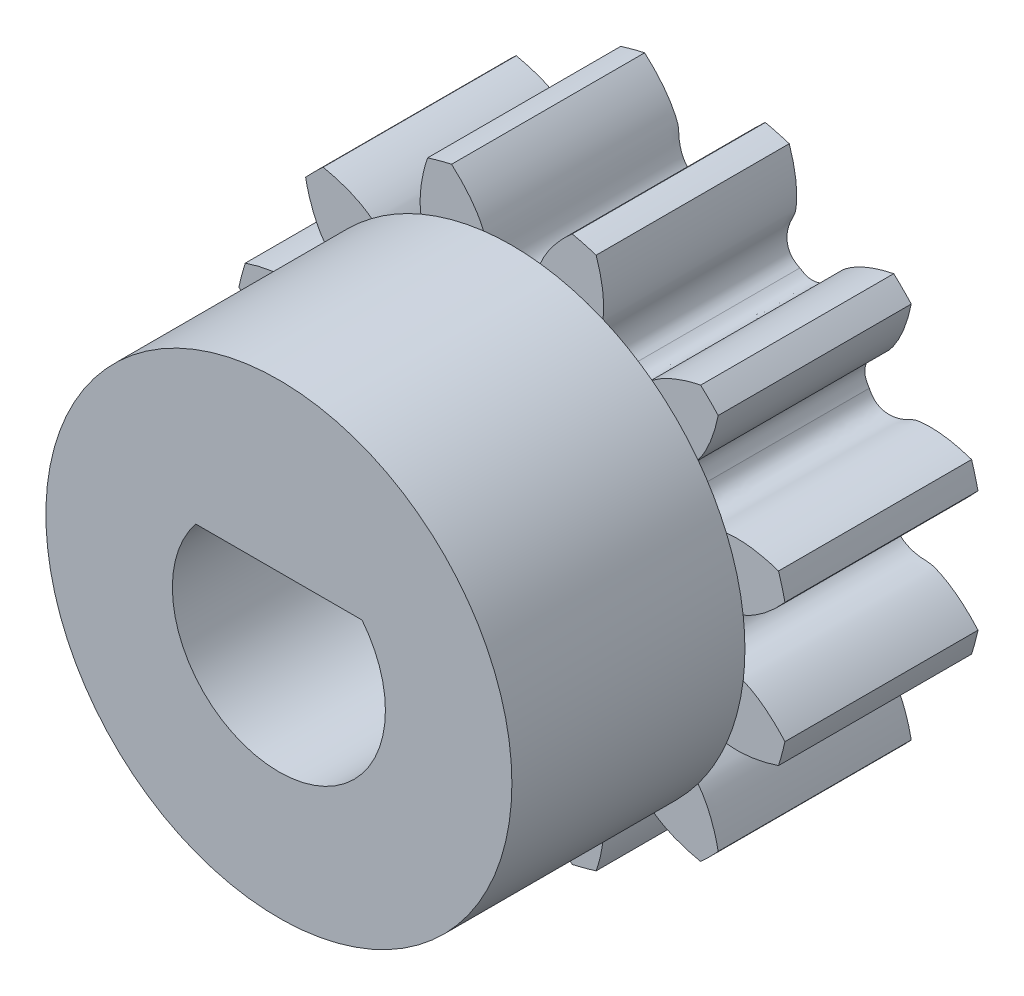
from build123d import *
from build123d.topology import SkipClean

# Parameters (mm, degrees)
SKETCH_343_R              = 4.200003307
F_0_6_7_2000MM_P_D_DEPTH  = 1.45
CUT_EXTRUDE_20_DEPTH      = 2.45
CUT_EXTRUDE_20_DEPTH_BACK = 2.45
CUT_EXTRUDE_2_DEPTH       = 10
SKETCH_4_R                = 3.5
EXTRUDE_2_DEPTH           = 3.5


with BuildPart() as part:
    # Sketch 343 → 0.6 _ _ 7.2000mm P.D (new body, symmetric)
    with BuildSketch(Plane.XY):
        Circle(SKETCH_343_R)
    extrude(amount=F_0_6_7_2000MM_P_D_DEPTH, both=True)

    # 0.0000mm → Cut-Extrude 20 (cut, two sides)
    with BuildSketch(Plane.XY) as cut_extrude_20_sk:
        with BuildLine():
            ThreePointArc((-0.980951061, 4.164094049), (0, 4.278077165), (0.980951061, 4.164094049))
            add(Edge.make_bspline(
                [(0.980951061, 4.164094049), (0.915611884, 4.111170814), (0.824718116, 4.030076692), (0.71684965, 3.917068577), (0.649240464, 3.838505988), (0.591283339, 3.76369244), (0.542402672, 3.693394784), (0.501946835, 3.628332868), (0.469288119, 3.569160893), (0.443531192, 3.516511442), (0.42440397, 3.470851313), (0.38949988, 3.380761712), (0.395272083, 3.288362832), (0.38267198, 3.20388663), (0.377498253, 3.175721911), (0.369292435, 3.139639353), (0.356530301, 3.096353741), (0.336683308, 3.047043485), (0.31191175, 3.000794089), (0.281311835, 2.957751799), (0.24360742, 2.918535628), (0.197429226, 2.884922105), (0.117695839, 2.848398305), (0.047163704, 2.847285128), (0, 2.849428724)],
                knots=[0, 0, 0, 0, 0.144025596, 0.208322738, 0.267476109, 0.32148571, 0.37035154, 0.414073599, 0.452651888, 0.486086407, 0.514377157, 0.537524137, 0.650875007, 0.667585775, 0.683918061, 0.699901684, 0.730957864, 0.761104196, 0.790795412, 0.820619897, 0.851292651, 0.883561769, 0.917947627, 1, 1, 1, 1], degree=3))
            add(Edge.make_bspline(
                [(-0.980951061, 4.164094049), (-0.915611884, 4.111170814), (-0.824718116, 4.030076692), (-0.71684965, 3.917068577), (-0.649240464, 3.838505988), (-0.591283339, 3.76369244), (-0.542402672, 3.693394784), (-0.501946835, 3.628332868), (-0.469288119, 3.569160893), (-0.443531192, 3.516511442), (-0.42440397, 3.470851313), (-0.38949988, 3.380761712), (-0.395272083, 3.288362832), (-0.38267198, 3.20388663), (-0.377498253, 3.175721911), (-0.369292435, 3.139639353), (-0.356530301, 3.096353741), (-0.336683308, 3.047043485), (-0.31191175, 3.000794089), (-0.281311835, 2.957751799), (-0.24360742, 2.918535628), (-0.197429226, 2.884922105), (-0.117695839, 2.848398305), (-0.047163704, 2.847285128), (0, 2.849428724)],
                knots=[0, 0, 0, 0, 0.144025596, 0.208322738, 0.267476109, 0.32148571, 0.37035154, 0.414073599, 0.452651888, 0.486086407, 0.514377157, 0.537524137, 0.650875007, 0.667585775, 0.683918061, 0.699901684, 0.730957864, 0.761104196, 0.790795412, 0.820619897, 0.851292651, 0.883561769, 0.917947627, 1, 1, 1, 1], degree=3))
        make_face()
        with BuildLine():
            ThreePointArc((1.232518486, 4.096686761), (2.139038583, 3.704923504), (2.931575563, 3.1157357))
            add(Edge.make_bspline(
                [(2.931575563, 3.1157357), (2.848528558, 3.102572422), (2.729265186, 3.077789736), (2.579344296, 3.033856071), (2.481511729, 2.999623466), (2.393912612, 2.963811595), (2.316431885, 2.927372373), (2.248865144, 2.89125502), (2.19099588, 2.856339944), (2.142365001, 2.823622645), (2.102970276, 2.793643425), (2.027697647, 2.733075586), (1.986497081, 2.650169708), (1.933346971, 2.583311222), (1.914784033, 2.561506724), (1.889636307, 2.534361221), (1.856941168, 2.503255849), (1.81509804, 2.470475411), (1.770520543, 2.442808038), (1.722499095, 2.420832278), (1.670238028, 2.405722285), (1.613439778, 2.399701217), (1.526126739, 2.407937372), (1.46448753, 2.442239401), (1.424714362, 2.467677661)],
                knots=[0, 0, 0, 0, 0.144025596, 0.208322738, 0.267476109, 0.32148571, 0.37035154, 0.414073599, 0.452651888, 0.486086407, 0.514377157, 0.537524137, 0.650875007, 0.667585775, 0.683918061, 0.699901684, 0.730957864, 0.761104196, 0.790795412, 0.820619897, 0.851292651, 0.883561769, 0.917947627, 1, 1, 1, 1], degree=3))
            add(Edge.make_bspline(
                [(1.232518486, 4.096686761), (1.262642256, 4.018184306), (1.300811506, 3.902507853), (1.337724281, 3.750705721), (1.356994259, 3.64886393), (1.369779827, 3.555094934), (1.376962899, 3.469775045), (1.379467724, 3.393201855), (1.378165014, 3.325628064), (1.374146441, 3.267153838), (1.367881037, 3.218047395), (1.353064065, 3.122575466), (1.301865751, 3.04544179), (1.270539659, 2.965983203), (1.260937878, 2.939004977), (1.250003046, 2.903653656), (1.239412573, 2.859786149), (1.231945445, 2.807158719), (1.230273545, 2.754719787), (1.235252704, 2.702144113), (1.248297599, 2.649329706), (1.271482327, 2.597130444), (1.322271566, 2.525633212), (1.382797599, 2.489403105), (1.424714362, 2.467677661)],
                knots=[0, 0, 0, 0, 0.144025596, 0.208322738, 0.267476109, 0.32148571, 0.37035154, 0.414073599, 0.452651888, 0.486086407, 0.514377157, 0.537524137, 0.650875007, 0.667585775, 0.683918061, 0.699901684, 0.730957864, 0.761104196, 0.790795412, 0.820619897, 0.851292651, 0.883561769, 0.917947627, 1, 1, 1, 1], degree=3))
        make_face()
        with BuildLine():
            ThreePointArc((3.1157357, 2.931575563), (3.704923504, 2.139038583), (4.096686761, 1.232518486))
            add(Edge.make_bspline(
                [(4.096686761, 1.232518486), (4.018184306, 1.262642256), (3.902507853, 1.300811506), (3.750705721, 1.337724281), (3.64886393, 1.356994259), (3.555094934, 1.369779827), (3.469775045, 1.376962899), (3.393201855, 1.379467724), (3.325628064, 1.378165014), (3.267153838, 1.374146441), (3.218047395, 1.367881037), (3.122575466, 1.353064065), (3.04544179, 1.301865751), (2.965983203, 1.270539659), (2.939004977, 1.260937878), (2.903653656, 1.250003046), (2.859786149, 1.239412573), (2.807158719, 1.231945445), (2.754719787, 1.230273545), (2.702144113, 1.235252704), (2.649329706, 1.248297599), (2.597130444, 1.271482327), (2.525633212, 1.322271566), (2.489403105, 1.382797599), (2.467677661, 1.424714362)],
                knots=[0, 0, 0, 0, 0.144025596, 0.208322738, 0.267476109, 0.32148571, 0.37035154, 0.414073599, 0.452651888, 0.486086407, 0.514377157, 0.537524137, 0.650875007, 0.667585775, 0.683918061, 0.699901684, 0.730957864, 0.761104196, 0.790795412, 0.820619897, 0.851292651, 0.883561769, 0.917947627, 1, 1, 1, 1], degree=3))
            add(Edge.make_bspline(
                [(3.1157357, 2.931575563), (3.102572422, 2.848528558), (3.077789736, 2.729265186), (3.033856071, 2.579344296), (2.999623466, 2.481511729), (2.963811595, 2.393912612), (2.927372373, 2.316431885), (2.89125502, 2.248865144), (2.856339944, 2.19099588), (2.823622645, 2.142365001), (2.793643425, 2.102970276), (2.733075586, 2.027697647), (2.650169708, 1.986497081), (2.583311222, 1.933346971), (2.561506724, 1.914784033), (2.534361221, 1.889636307), (2.503255849, 1.856941168), (2.470475411, 1.81509804), (2.442808038, 1.770520543), (2.420832278, 1.722499095), (2.405722285, 1.670238028), (2.399701217, 1.613439778), (2.407937372, 1.526126739), (2.442239401, 1.46448753), (2.467677661, 1.424714362)],
                knots=[0, 0, 0, 0, 0.144025596, 0.208322738, 0.267476109, 0.32148571, 0.37035154, 0.414073599, 0.452651888, 0.486086407, 0.514377157, 0.537524137, 0.650875007, 0.667585775, 0.683918061, 0.699901684, 0.730957864, 0.761104196, 0.790795412, 0.820619897, 0.851292651, 0.883561769, 0.917947627, 1, 1, 1, 1], degree=3))
        make_face()
        with BuildLine():
            ThreePointArc((4.164094049, 0.980951061), (4.278077165, 0), (4.164094049, -0.980951061))
            add(Edge.make_bspline(
                [(4.164094049, -0.980951061), (4.111170814, -0.915611884), (4.030076692, -0.824718116), (3.917068577, -0.71684965), (3.838505988, -0.649240464), (3.76369244, -0.591283339), (3.693394784, -0.542402672), (3.628332868, -0.501946835), (3.569160893, -0.469288119), (3.516511442, -0.443531192), (3.470851313, -0.42440397), (3.380761712, -0.38949988), (3.288362832, -0.395272083), (3.20388663, -0.38267198), (3.175721911, -0.377498253), (3.139639353, -0.369292435), (3.096353741, -0.356530301), (3.047043485, -0.336683308), (3.000794089, -0.31191175), (2.957751799, -0.281311835), (2.918535628, -0.24360742), (2.884922105, -0.197429226), (2.848398305, -0.117695839), (2.847285128, -0.047163704), (2.849428724, 0)],
                knots=[0, 0, 0, 0, 0.144025596, 0.208322738, 0.267476109, 0.32148571, 0.37035154, 0.414073599, 0.452651888, 0.486086407, 0.514377157, 0.537524137, 0.650875007, 0.667585775, 0.683918061, 0.699901684, 0.730957864, 0.761104196, 0.790795412, 0.820619897, 0.851292651, 0.883561769, 0.917947627, 1, 1, 1, 1], degree=3))
            add(Edge.make_bspline(
                [(4.164094049, 0.980951061), (4.111170814, 0.915611884), (4.030076692, 0.824718116), (3.917068577, 0.71684965), (3.838505988, 0.649240464), (3.76369244, 0.591283339), (3.693394784, 0.542402672), (3.628332868, 0.501946835), (3.569160893, 0.469288119), (3.516511442, 0.443531192), (3.470851313, 0.42440397), (3.380761712, 0.38949988), (3.288362832, 0.395272083), (3.20388663, 0.38267198), (3.175721911, 0.377498253), (3.139639353, 0.369292435), (3.096353741, 0.356530301), (3.047043485, 0.336683308), (3.000794089, 0.31191175), (2.957751799, 0.281311835), (2.918535628, 0.24360742), (2.884922105, 0.197429226), (2.848398305, 0.117695839), (2.847285128, 0.047163704), (2.849428724, 0)],
                knots=[0, 0, 0, 0, 0.144025596, 0.208322738, 0.267476109, 0.32148571, 0.37035154, 0.414073599, 0.452651888, 0.486086407, 0.514377157, 0.537524137, 0.650875007, 0.667585775, 0.683918061, 0.699901684, 0.730957864, 0.761104196, 0.790795412, 0.820619897, 0.851292651, 0.883561769, 0.917947627, 1, 1, 1, 1], degree=3))
        make_face()
        with BuildLine():
            ThreePointArc((4.096686761, -1.232518486), (3.704923504, -2.139038583), (3.1157357, -2.931575563))
            add(Edge.make_bspline(
                [(3.1157357, -2.931575563), (3.102572422, -2.848528558), (3.077789736, -2.729265186), (3.033856071, -2.579344296), (2.999623466, -2.481511729), (2.963811595, -2.393912612), (2.927372373, -2.316431885), (2.89125502, -2.248865144), (2.856339944, -2.19099588), (2.823622645, -2.142365001), (2.793643425, -2.102970276), (2.733075586, -2.027697647), (2.650169708, -1.986497081), (2.583311222, -1.933346971), (2.561506724, -1.914784033), (2.534361221, -1.889636307), (2.503255849, -1.856941168), (2.470475411, -1.81509804), (2.442808038, -1.770520543), (2.420832278, -1.722499095), (2.405722285, -1.670238028), (2.399701217, -1.613439778), (2.407937372, -1.526126739), (2.442239401, -1.46448753), (2.467677661, -1.424714362)],
                knots=[0, 0, 0, 0, 0.144025596, 0.208322738, 0.267476109, 0.32148571, 0.37035154, 0.414073599, 0.452651888, 0.486086407, 0.514377157, 0.537524137, 0.650875007, 0.667585775, 0.683918061, 0.699901684, 0.730957864, 0.761104196, 0.790795412, 0.820619897, 0.851292651, 0.883561769, 0.917947627, 1, 1, 1, 1], degree=3))
            add(Edge.make_bspline(
                [(4.096686761, -1.232518486), (4.018184306, -1.262642256), (3.902507853, -1.300811506), (3.750705721, -1.337724281), (3.64886393, -1.356994259), (3.555094934, -1.369779827), (3.469775045, -1.376962899), (3.393201855, -1.379467724), (3.325628064, -1.378165014), (3.267153838, -1.374146441), (3.218047395, -1.367881037), (3.122575466, -1.353064065), (3.04544179, -1.301865751), (2.965983203, -1.270539659), (2.939004977, -1.260937878), (2.903653656, -1.250003046), (2.859786149, -1.239412573), (2.807158719, -1.231945445), (2.754719787, -1.230273545), (2.702144113, -1.235252704), (2.649329706, -1.248297599), (2.597130444, -1.271482327), (2.525633212, -1.322271566), (2.489403105, -1.382797599), (2.467677661, -1.424714362)],
                knots=[0, 0, 0, 0, 0.144025596, 0.208322738, 0.267476109, 0.32148571, 0.37035154, 0.414073599, 0.452651888, 0.486086407, 0.514377157, 0.537524137, 0.650875007, 0.667585775, 0.683918061, 0.699901684, 0.730957864, 0.761104196, 0.790795412, 0.820619897, 0.851292651, 0.883561769, 0.917947627, 1, 1, 1, 1], degree=3))
        make_face()
        with BuildLine():
            ThreePointArc((2.931575563, -3.1157357), (2.139038583, -3.704923504), (1.232518486, -4.096686761))
            add(Edge.make_bspline(
                [(1.232518486, -4.096686761), (1.262642256, -4.018184306), (1.300811506, -3.902507853), (1.337724281, -3.750705721), (1.356994259, -3.64886393), (1.369779827, -3.555094934), (1.376962899, -3.469775045), (1.379467724, -3.393201855), (1.378165014, -3.325628064), (1.374146441, -3.267153838), (1.367881037, -3.218047395), (1.353064065, -3.122575466), (1.301865751, -3.04544179), (1.270539659, -2.965983203), (1.260937878, -2.939004977), (1.250003046, -2.903653656), (1.239412573, -2.859786149), (1.231945445, -2.807158719), (1.230273545, -2.754719787), (1.235252704, -2.702144113), (1.248297599, -2.649329706), (1.271482327, -2.597130444), (1.322271566, -2.525633212), (1.382797599, -2.489403105), (1.424714362, -2.467677661)],
                knots=[0, 0, 0, 0, 0.144025596, 0.208322738, 0.267476109, 0.32148571, 0.37035154, 0.414073599, 0.452651888, 0.486086407, 0.514377157, 0.537524137, 0.650875007, 0.667585775, 0.683918061, 0.699901684, 0.730957864, 0.761104196, 0.790795412, 0.820619897, 0.851292651, 0.883561769, 0.917947627, 1, 1, 1, 1], degree=3))
            add(Edge.make_bspline(
                [(2.931575563, -3.1157357), (2.848528558, -3.102572422), (2.729265186, -3.077789736), (2.579344296, -3.033856071), (2.481511729, -2.999623466), (2.393912612, -2.963811595), (2.316431885, -2.927372373), (2.248865144, -2.89125502), (2.19099588, -2.856339944), (2.142365001, -2.823622645), (2.102970276, -2.793643425), (2.027697647, -2.733075586), (1.986497081, -2.650169708), (1.933346971, -2.583311222), (1.914784033, -2.561506724), (1.889636307, -2.534361221), (1.856941168, -2.503255849), (1.81509804, -2.470475411), (1.770520543, -2.442808038), (1.722499095, -2.420832278), (1.670238028, -2.405722285), (1.613439778, -2.399701217), (1.526126739, -2.407937372), (1.46448753, -2.442239401), (1.424714362, -2.467677661)],
                knots=[0, 0, 0, 0, 0.144025596, 0.208322738, 0.267476109, 0.32148571, 0.37035154, 0.414073599, 0.452651888, 0.486086407, 0.514377157, 0.537524137, 0.650875007, 0.667585775, 0.683918061, 0.699901684, 0.730957864, 0.761104196, 0.790795412, 0.820619897, 0.851292651, 0.883561769, 0.917947627, 1, 1, 1, 1], degree=3))
        make_face()
        with BuildLine():
            ThreePointArc((0.980951061, -4.164094049), (0, -4.278077165), (-0.980951061, -4.164094049))
            add(Edge.make_bspline(
                [(-0.980951061, -4.164094049), (-0.915611884, -4.111170814), (-0.824718116, -4.030076692), (-0.71684965, -3.917068577), (-0.649240464, -3.838505988), (-0.591283339, -3.76369244), (-0.542402672, -3.693394784), (-0.501946835, -3.628332868), (-0.469288119, -3.569160893), (-0.443531192, -3.516511442), (-0.42440397, -3.470851313), (-0.38949988, -3.380761712), (-0.395272083, -3.288362832), (-0.38267198, -3.20388663), (-0.377498253, -3.175721911), (-0.369292435, -3.139639353), (-0.356530301, -3.096353741), (-0.336683308, -3.047043485), (-0.31191175, -3.000794089), (-0.281311835, -2.957751799), (-0.24360742, -2.918535628), (-0.197429226, -2.884922105), (-0.117695839, -2.848398305), (-0.047163704, -2.847285128), (0, -2.849428724)],
                knots=[0, 0, 0, 0, 0.144025596, 0.208322738, 0.267476109, 0.32148571, 0.37035154, 0.414073599, 0.452651888, 0.486086407, 0.514377157, 0.537524137, 0.650875007, 0.667585775, 0.683918061, 0.699901684, 0.730957864, 0.761104196, 0.790795412, 0.820619897, 0.851292651, 0.883561769, 0.917947627, 1, 1, 1, 1], degree=3))
            add(Edge.make_bspline(
                [(0.980951061, -4.164094049), (0.915611884, -4.111170814), (0.824718116, -4.030076692), (0.71684965, -3.917068577), (0.649240464, -3.838505988), (0.591283339, -3.76369244), (0.542402672, -3.693394784), (0.501946835, -3.628332868), (0.469288119, -3.569160893), (0.443531192, -3.516511442), (0.42440397, -3.470851313), (0.38949988, -3.380761712), (0.395272083, -3.288362832), (0.38267198, -3.20388663), (0.377498253, -3.175721911), (0.369292435, -3.139639353), (0.356530301, -3.096353741), (0.336683308, -3.047043485), (0.31191175, -3.000794089), (0.281311835, -2.957751799), (0.24360742, -2.918535628), (0.197429226, -2.884922105), (0.117695839, -2.848398305), (0.047163704, -2.847285128), (0, -2.849428724)],
                knots=[0, 0, 0, 0, 0.144025596, 0.208322738, 0.267476109, 0.32148571, 0.37035154, 0.414073599, 0.452651888, 0.486086407, 0.514377157, 0.537524137, 0.650875007, 0.667585775, 0.683918061, 0.699901684, 0.730957864, 0.761104196, 0.790795412, 0.820619897, 0.851292651, 0.883561769, 0.917947627, 1, 1, 1, 1], degree=3))
        make_face()
        with BuildLine():
            ThreePointArc((-1.232518486, -4.096686761), (-2.139038583, -3.704923504), (-2.931575563, -3.1157357))
            add(Edge.make_bspline(
                [(-2.931575563, -3.1157357), (-2.848528558, -3.102572422), (-2.729265186, -3.077789736), (-2.579344296, -3.033856071), (-2.481511729, -2.999623466), (-2.393912612, -2.963811595), (-2.316431885, -2.927372373), (-2.248865144, -2.89125502), (-2.19099588, -2.856339944), (-2.142365001, -2.823622645), (-2.102970276, -2.793643425), (-2.027697647, -2.733075586), (-1.986497081, -2.650169708), (-1.933346971, -2.583311222), (-1.914784033, -2.561506724), (-1.889636307, -2.534361221), (-1.856941168, -2.503255849), (-1.81509804, -2.470475411), (-1.770520543, -2.442808038), (-1.722499095, -2.420832278), (-1.670238028, -2.405722285), (-1.613439778, -2.399701217), (-1.526126739, -2.407937372), (-1.46448753, -2.442239401), (-1.424714362, -2.467677661)],
                knots=[0, 0, 0, 0, 0.144025596, 0.208322738, 0.267476109, 0.32148571, 0.37035154, 0.414073599, 0.452651888, 0.486086407, 0.514377157, 0.537524137, 0.650875007, 0.667585775, 0.683918061, 0.699901684, 0.730957864, 0.761104196, 0.790795412, 0.820619897, 0.851292651, 0.883561769, 0.917947627, 1, 1, 1, 1], degree=3))
            add(Edge.make_bspline(
                [(-1.232518486, -4.096686761), (-1.262642256, -4.018184306), (-1.300811506, -3.902507853), (-1.337724281, -3.750705721), (-1.356994259, -3.64886393), (-1.369779827, -3.555094934), (-1.376962899, -3.469775045), (-1.379467724, -3.393201855), (-1.378165014, -3.325628064), (-1.374146441, -3.267153838), (-1.367881037, -3.218047395), (-1.353064065, -3.122575466), (-1.301865751, -3.04544179), (-1.270539659, -2.965983203), (-1.260937878, -2.939004977), (-1.250003046, -2.903653656), (-1.239412573, -2.859786149), (-1.231945445, -2.807158719), (-1.230273545, -2.754719787), (-1.235252704, -2.702144113), (-1.248297599, -2.649329706), (-1.271482327, -2.597130444), (-1.322271566, -2.525633212), (-1.382797599, -2.489403105), (-1.424714362, -2.467677661)],
                knots=[0, 0, 0, 0, 0.144025596, 0.208322738, 0.267476109, 0.32148571, 0.37035154, 0.414073599, 0.452651888, 0.486086407, 0.514377157, 0.537524137, 0.650875007, 0.667585775, 0.683918061, 0.699901684, 0.730957864, 0.761104196, 0.790795412, 0.820619897, 0.851292651, 0.883561769, 0.917947627, 1, 1, 1, 1], degree=3))
        make_face()
        with BuildLine():
            ThreePointArc((-3.1157357, -2.931575563), (-3.704923504, -2.139038583), (-4.096686761, -1.232518486))
            add(Edge.make_bspline(
                [(-4.096686761, -1.232518486), (-4.018184306, -1.262642256), (-3.902507853, -1.300811506), (-3.750705721, -1.337724281), (-3.64886393, -1.356994259), (-3.555094934, -1.369779827), (-3.469775045, -1.376962899), (-3.393201855, -1.379467724), (-3.325628064, -1.378165014), (-3.267153838, -1.374146441), (-3.218047395, -1.367881037), (-3.122575466, -1.353064065), (-3.04544179, -1.301865751), (-2.965983203, -1.270539659), (-2.939004977, -1.260937878), (-2.903653656, -1.250003046), (-2.859786149, -1.239412573), (-2.807158719, -1.231945445), (-2.754719787, -1.230273545), (-2.702144113, -1.235252704), (-2.649329706, -1.248297599), (-2.597130444, -1.271482327), (-2.525633212, -1.322271566), (-2.489403105, -1.382797599), (-2.467677661, -1.424714362)],
                knots=[0, 0, 0, 0, 0.144025596, 0.208322738, 0.267476109, 0.32148571, 0.37035154, 0.414073599, 0.452651888, 0.486086407, 0.514377157, 0.537524137, 0.650875007, 0.667585775, 0.683918061, 0.699901684, 0.730957864, 0.761104196, 0.790795412, 0.820619897, 0.851292651, 0.883561769, 0.917947627, 1, 1, 1, 1], degree=3))
            add(Edge.make_bspline(
                [(-3.1157357, -2.931575563), (-3.102572422, -2.848528558), (-3.077789736, -2.729265186), (-3.033856071, -2.579344296), (-2.999623466, -2.481511729), (-2.963811595, -2.393912612), (-2.927372373, -2.316431885), (-2.89125502, -2.248865144), (-2.856339944, -2.19099588), (-2.823622645, -2.142365001), (-2.793643425, -2.102970276), (-2.733075586, -2.027697647), (-2.650169708, -1.986497081), (-2.583311222, -1.933346971), (-2.561506724, -1.914784033), (-2.534361221, -1.889636307), (-2.503255849, -1.856941168), (-2.470475411, -1.81509804), (-2.442808038, -1.770520543), (-2.420832278, -1.722499095), (-2.405722285, -1.670238028), (-2.399701217, -1.613439778), (-2.407937372, -1.526126739), (-2.442239401, -1.46448753), (-2.467677661, -1.424714362)],
                knots=[0, 0, 0, 0, 0.144025596, 0.208322738, 0.267476109, 0.32148571, 0.37035154, 0.414073599, 0.452651888, 0.486086407, 0.514377157, 0.537524137, 0.650875007, 0.667585775, 0.683918061, 0.699901684, 0.730957864, 0.761104196, 0.790795412, 0.820619897, 0.851292651, 0.883561769, 0.917947627, 1, 1, 1, 1], degree=3))
        make_face()
        with BuildLine():
            ThreePointArc((-4.164094049, -0.980951061), (-4.278077165, 0), (-4.164094049, 0.980951061))
            add(Edge.make_bspline(
                [(-4.164094049, 0.980951061), (-4.111170814, 0.915611884), (-4.030076692, 0.824718116), (-3.917068577, 0.71684965), (-3.838505988, 0.649240464), (-3.76369244, 0.591283339), (-3.693394784, 0.542402672), (-3.628332868, 0.501946835), (-3.569160893, 0.469288119), (-3.516511442, 0.443531192), (-3.470851313, 0.42440397), (-3.380761712, 0.38949988), (-3.288362832, 0.395272083), (-3.20388663, 0.38267198), (-3.175721911, 0.377498253), (-3.139639353, 0.369292435), (-3.096353741, 0.356530301), (-3.047043485, 0.336683308), (-3.000794089, 0.31191175), (-2.957751799, 0.281311835), (-2.918535628, 0.24360742), (-2.884922105, 0.197429226), (-2.848398305, 0.117695839), (-2.847285128, 0.047163704), (-2.849428724, 0)],
                knots=[0, 0, 0, 0, 0.144025596, 0.208322738, 0.267476109, 0.32148571, 0.37035154, 0.414073599, 0.452651888, 0.486086407, 0.514377157, 0.537524137, 0.650875007, 0.667585775, 0.683918061, 0.699901684, 0.730957864, 0.761104196, 0.790795412, 0.820619897, 0.851292651, 0.883561769, 0.917947627, 1, 1, 1, 1], degree=3))
            add(Edge.make_bspline(
                [(-4.164094049, -0.980951061), (-4.111170814, -0.915611884), (-4.030076692, -0.824718116), (-3.917068577, -0.71684965), (-3.838505988, -0.649240464), (-3.76369244, -0.591283339), (-3.693394784, -0.542402672), (-3.628332868, -0.501946835), (-3.569160893, -0.469288119), (-3.516511442, -0.443531192), (-3.470851313, -0.42440397), (-3.380761712, -0.38949988), (-3.288362832, -0.395272083), (-3.20388663, -0.38267198), (-3.175721911, -0.377498253), (-3.139639353, -0.369292435), (-3.096353741, -0.356530301), (-3.047043485, -0.336683308), (-3.000794089, -0.31191175), (-2.957751799, -0.281311835), (-2.918535628, -0.24360742), (-2.884922105, -0.197429226), (-2.848398305, -0.117695839), (-2.847285128, -0.047163704), (-2.849428724, 0)],
                knots=[0, 0, 0, 0, 0.144025596, 0.208322738, 0.267476109, 0.32148571, 0.37035154, 0.414073599, 0.452651888, 0.486086407, 0.514377157, 0.537524137, 0.650875007, 0.667585775, 0.683918061, 0.699901684, 0.730957864, 0.761104196, 0.790795412, 0.820619897, 0.851292651, 0.883561769, 0.917947627, 1, 1, 1, 1], degree=3))
        make_face()
        with BuildLine():
            ThreePointArc((-4.096686761, 1.232518486), (-3.704923504, 2.139038583), (-3.1157357, 2.931575563))
            add(Edge.make_bspline(
                [(-3.1157357, 2.931575563), (-3.102572422, 2.848528558), (-3.077789736, 2.729265186), (-3.033856071, 2.579344296), (-2.999623466, 2.481511729), (-2.963811595, 2.393912612), (-2.927372373, 2.316431885), (-2.89125502, 2.248865144), (-2.856339944, 2.19099588), (-2.823622645, 2.142365001), (-2.793643425, 2.102970276), (-2.733075586, 2.027697647), (-2.650169708, 1.986497081), (-2.583311222, 1.933346971), (-2.561506724, 1.914784033), (-2.534361221, 1.889636307), (-2.503255849, 1.856941168), (-2.470475411, 1.81509804), (-2.442808038, 1.770520543), (-2.420832278, 1.722499095), (-2.405722285, 1.670238028), (-2.399701217, 1.613439778), (-2.407937372, 1.526126739), (-2.442239401, 1.46448753), (-2.467677661, 1.424714362)],
                knots=[0, 0, 0, 0, 0.144025596, 0.208322738, 0.267476109, 0.32148571, 0.37035154, 0.414073599, 0.452651888, 0.486086407, 0.514377157, 0.537524137, 0.650875007, 0.667585775, 0.683918061, 0.699901684, 0.730957864, 0.761104196, 0.790795412, 0.820619897, 0.851292651, 0.883561769, 0.917947627, 1, 1, 1, 1], degree=3))
            add(Edge.make_bspline(
                [(-4.096686761, 1.232518486), (-4.018184306, 1.262642256), (-3.902507853, 1.300811506), (-3.750705721, 1.337724281), (-3.64886393, 1.356994259), (-3.555094934, 1.369779827), (-3.469775045, 1.376962899), (-3.393201855, 1.379467724), (-3.325628064, 1.378165014), (-3.267153838, 1.374146441), (-3.218047395, 1.367881037), (-3.122575466, 1.353064065), (-3.04544179, 1.301865751), (-2.965983203, 1.270539659), (-2.939004977, 1.260937878), (-2.903653656, 1.250003046), (-2.859786149, 1.239412573), (-2.807158719, 1.231945445), (-2.754719787, 1.230273545), (-2.702144113, 1.235252704), (-2.649329706, 1.248297599), (-2.597130444, 1.271482327), (-2.525633212, 1.322271566), (-2.489403105, 1.382797599), (-2.467677661, 1.424714362)],
                knots=[0, 0, 0, 0, 0.144025596, 0.208322738, 0.267476109, 0.32148571, 0.37035154, 0.414073599, 0.452651888, 0.486086407, 0.514377157, 0.537524137, 0.650875007, 0.667585775, 0.683918061, 0.699901684, 0.730957864, 0.761104196, 0.790795412, 0.820619897, 0.851292651, 0.883561769, 0.917947627, 1, 1, 1, 1], degree=3))
        make_face()
        with BuildLine():
            ThreePointArc((-2.931575563, 3.1157357), (-2.139038583, 3.704923504), (-1.232518486, 4.096686761))
            add(Edge.make_bspline(
                [(-1.232518486, 4.096686761), (-1.262642256, 4.018184306), (-1.300811506, 3.902507853), (-1.337724281, 3.750705721), (-1.356994259, 3.64886393), (-1.369779827, 3.555094934), (-1.376962899, 3.469775045), (-1.379467724, 3.393201855), (-1.378165014, 3.325628064), (-1.374146441, 3.267153838), (-1.367881037, 3.218047395), (-1.353064065, 3.122575466), (-1.301865751, 3.04544179), (-1.270539659, 2.965983203), (-1.260937878, 2.939004977), (-1.250003046, 2.903653656), (-1.239412573, 2.859786149), (-1.231945445, 2.807158719), (-1.230273545, 2.754719787), (-1.235252704, 2.702144113), (-1.248297599, 2.649329706), (-1.271482327, 2.597130444), (-1.322271566, 2.525633212), (-1.382797599, 2.489403105), (-1.424714362, 2.467677661)],
                knots=[0, 0, 0, 0, 0.144025596, 0.208322738, 0.267476109, 0.32148571, 0.37035154, 0.414073599, 0.452651888, 0.486086407, 0.514377157, 0.537524137, 0.650875007, 0.667585775, 0.683918061, 0.699901684, 0.730957864, 0.761104196, 0.790795412, 0.820619897, 0.851292651, 0.883561769, 0.917947627, 1, 1, 1, 1], degree=3))
            add(Edge.make_bspline(
                [(-2.931575563, 3.1157357), (-2.848528558, 3.102572422), (-2.729265186, 3.077789736), (-2.579344296, 3.033856071), (-2.481511729, 2.999623466), (-2.393912612, 2.963811595), (-2.316431885, 2.927372373), (-2.248865144, 2.89125502), (-2.19099588, 2.856339944), (-2.142365001, 2.823622645), (-2.102970276, 2.793643425), (-2.027697647, 2.733075586), (-1.986497081, 2.650169708), (-1.933346971, 2.583311222), (-1.914784033, 2.561506724), (-1.889636307, 2.534361221), (-1.856941168, 2.503255849), (-1.81509804, 2.470475411), (-1.770520543, 2.442808038), (-1.722499095, 2.420832278), (-1.670238028, 2.405722285), (-1.613439778, 2.399701217), (-1.526126739, 2.407937372), (-1.46448753, 2.442239401), (-1.424714362, 2.467677661)],
                knots=[0, 0, 0, 0, 0.144025596, 0.208322738, 0.267476109, 0.32148571, 0.37035154, 0.414073599, 0.452651888, 0.486086407, 0.514377157, 0.537524137, 0.650875007, 0.667585775, 0.683918061, 0.699901684, 0.730957864, 0.761104196, 0.790795412, 0.820619897, 0.851292651, 0.883561769, 0.917947627, 1, 1, 1, 1], degree=3))
        make_face()
    extrude(amount=CUT_EXTRUDE_20_DEPTH, mode=Mode.SUBTRACT)
    extrude(cut_extrude_20_sk.sketch, amount=-CUT_EXTRUDE_20_DEPTH_BACK, mode=Mode.SUBTRACT)

    # Sketch 3 → Cut-Extrude 2 (cut)
    with BuildSketch(Plane.XY.offset(1.45)):
        with BuildLine():
            Line((-1.2489996, 1), (1.2489996, 1))
            ThreePointArc((1.2489996, 1), (0, -1.6), (-1.2489996, 1))
        make_face()
    extrude(amount=-CUT_EXTRUDE_2_DEPTH, mode=Mode.SUBTRACT)

    # Sketch 4 → Extrude 2 (add)
    with SkipClean():  # keep this step's faces unmerged: merging them makes the solid invalid here
        with BuildSketch(Plane.XY.offset(1.45)):
            with Locations(Location((0, 0, 0), (0, 0, 186.989329133))):  # turned: the seam where the file's is
                Circle(SKETCH_4_R)
            with BuildLine():
                Line((1.2489996, 1), (-1.2489996, 1))
                ThreePointArc((-1.2489996, 1), (0, -1.6), (1.2489996, 1))
            make_face(mode=Mode.SUBTRACT)
        extrude(amount=EXTRUDE_2_DEPTH)


solid = part.part
